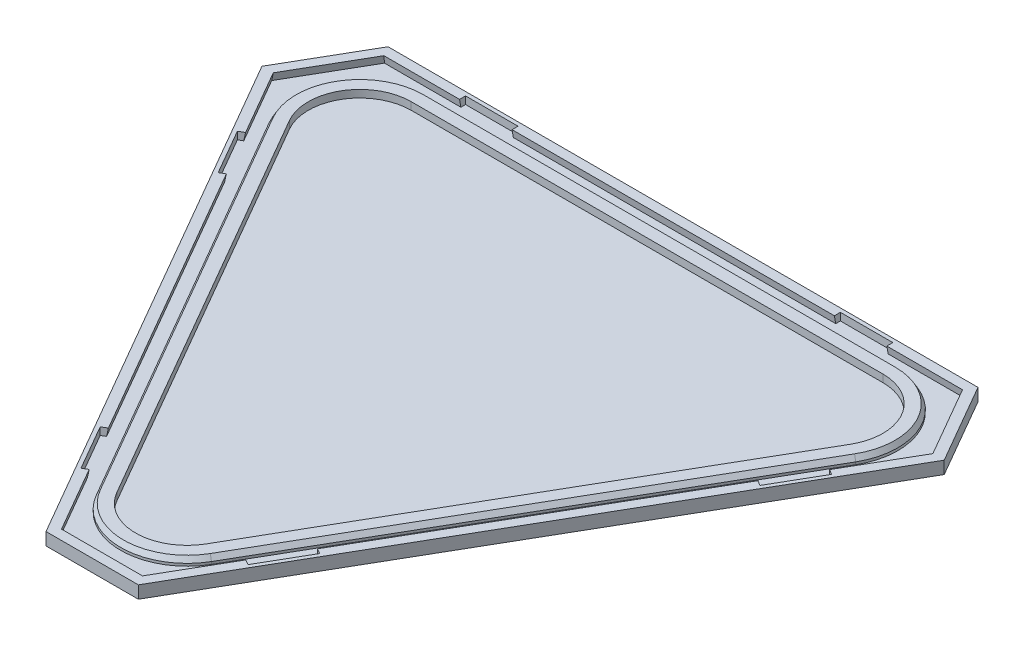
from build123d import *
from OCP.BRepFilletAPI import BRepFilletAPI_MakeChamfer

# Parameters (mm, degrees)
BOSS_EXTRU_2_DEPTH              = 1
EXTRU_MINCE1_DEPTH              = 1.5
EXTRU_MINCE1_DRAFT              = -10
ENL_V_DE_MAT_EXTRU_MINCE1_DEPTH = 101.734373448
ESQUISSE10_W                    = 10.5
ESQUISSE10_H                    = 4.277647959
ENL_V_MAT_EXTRU_1_DEPTH         = 1.5
EXTRU_MINCE2_DEPTH              = 1.5
CHANFREIN1_SIZE                 = 1
CHANFREIN1_SIZE2                = 0.577350269


with BuildPart() as part:
    # Esquisse2 → Boss.-Extru.2 (new body)
    with BuildSketch(Plane(origin=(0, 0, 0), x_dir=(1, 0, 0), z_dir=(0, 1, 0))):
        Polygon((-68.262395693, 28.744645862), (-59.024791386, 44.744645862), (59.024791386, 44.744645862), (68.262395693, 28.744645862), (9.237604307, -73.489291724), (-9.237604307, -73.489291724), align=None)
    extrude(amount=BOSS_EXTRU_2_DEPTH)


with BuildPart() as extru_mince1_tool:
    # Esquisse5 → Extru.-Mince1 (with draft: the straight prism first)
    with BuildSketch(Plane(origin=(0, 1, 0), x_dir=(1, 0, 0), z_dir=(0, 1, 0))):
        Polygon((-68.262395693, 28.744645862), (-9.237604307, -73.489291724), (9.237604307, -73.489291724), (68.262395693, 28.744645862), (59.024791386, 44.744645862), (-59.024791386, 44.744645862), align=None)
        Polygon((-66.299404778, 28.744645862), (-8.256108849, -71.789291724), (8.256108849, -71.789291724), (66.299404778, 28.744645862), (58.043295928, 43.044645862), (-58.043295928, 43.044645862), align=None, mode=Mode.SUBTRACT)
    extrude(amount=EXTRU_MINCE1_DEPTH)
    # Extru.-Mince1: the draft: its side faces are tilted about the plane it starts from
    extru_mince1_sides = [extru_mince1_tool.faces().sort_by_distance(p)[0] for p in [
        (-38.75, 1.75, 22.372322931),
        (0, 1.75, 73.489291724),
        (38.75, 1.75, 22.372322931),
        (63.643593539, 1.75, -36.744645862),
        (0, 1.75, -44.744645862),
        (-63.643593539, 1.75, -36.744645862),
        (-62.171350353, 1.75, -35.894645862),
        (0, 1.75, -43.044645862),
        (62.171350353, 1.75, -35.894645862),
        (37.277756814, 1.75, 21.522322931),
        (0, 1.75, 71.789291724),
        (-37.277756814, 1.75, 21.522322931),
    ]]
    draft(extru_mince1_sides, Plane(origin=(0, 1, 0), x_dir=(1, 0, 0), z_dir=(0, 1, 0)), EXTRU_MINCE1_DRAFT)


with BuildPart() as part_1:
    add(part.part)

    # Extru.-Mince1: add extru_mince1_tool
    add(extru_mince1_tool.part)

    # Esquisse6 → Enlèv. de mat.-Extru.-Mince1 (cut, through all)
    with BuildSketch(Plane.XZ):
        Polygon((-59.89081679, -46.244645862), (59.89081679, -46.244645862), (69.994446501, -28.744645862), (10.103629711, 74.989291724), (-10.103629711, 74.989291724), (-69.994446501, -28.744645862), align=None)
        Polygon((-59.024791386, -44.744645862), (59.024791386, -44.744645862), (68.262395693, -28.744645862), (9.237604307, 73.489291724), (-9.237604307, 73.489291724), (-68.262395693, -28.744645862), align=None, mode=Mode.SUBTRACT)
    extrude(amount=-ENL_V_DE_MAT_EXTRU_MINCE1_DEPTH, mode=Mode.SUBTRACT)

    # Esquisse10 → Enlèv. mat.-Extru.1 (cut)
    with BuildSketch(Plane(origin=(0, 2.5, 0), x_dir=(1, 0, 0), z_dir=(0, 1, 0))):
        with Locations((-37.5, 41.841331412)):
            Rectangle(ESQUISSE10_W, ESQUISSE10_H)
        with Locations((37.5, 41.841331412)):
            Rectangle(ESQUISSE10_W, ESQUISSE10_H)
        Polygon((54.212931831, 5.939241576), (59.462931831, 15.032508316), (55.75838003, 17.171332296), (50.50838003, 8.078065556), align=None)
        Polygon((16.712931831, -59.012663707), (13.00838003, -56.873839728), (18.25838003, -47.780572988), (21.962931831, -49.919396968), align=None)
        Polygon((-21.962931831, -49.919396968), (-16.712931831, -59.012663707), (-13.00838003, -56.873839728), (-18.25838003, -47.780572988), align=None)
        Polygon((-59.462931831, 15.032508316), (-55.75838003, 17.171332296), (-50.50838003, 8.078065556), (-54.212931831, 5.939241576), align=None)
    extrude(amount=-ENL_V_MAT_EXTRU_1_DEPTH, mode=Mode.SUBTRACT)


with BuildPart() as body_2:
    # Esquisse11 → Extru.-Mince2 (new body)
    with BuildSketch(Plane(origin=(0, 1, 0), x_dir=(1, 0, 0), z_dir=(0, 1, 0))):
        with BuildLine():
            Line((-58.707248738, 20.594645862), (-11.51813787, -61.139291724))
            ThreePointArc((-11.51813787, -61.139291724), (0, -67.789291724), (11.51813787, -61.139291724))
            Line((11.51813787, -61.139291724), (58.707248738, 20.594645862))
            ThreePointArc((58.707248738, 20.594645862), (58.707248738, 33.894645862), (47.189110868, 40.544645862))
            Line((47.189110868, 40.544645862), (-47.189110868, 40.544645862))
            ThreePointArc((-47.189110868, 40.544645862), (-58.707248738, 33.894645862), (-58.707248738, 20.594645862))
        make_face()
        with BuildLine():
            Line((-56.109172527, 22.094645862), (-8.920061659, -59.639291724))
            ThreePointArc((-8.920061659, -59.639291724), (0, -64.789291724), (8.920061659, -59.639291724))
            Line((8.920061659, -59.639291724), (56.109172527, 22.094645862))
            ThreePointArc((56.109172527, 22.094645862), (56.109172527, 32.394645862), (47.189110868, 37.544645862))
            Line((47.189110868, 37.544645862), (-47.189110868, 37.544645862))
            ThreePointArc((-47.189110868, 37.544645862), (-56.109172527, 32.394645862), (-56.109172527, 22.094645862))
        make_face(mode=Mode.SUBTRACT)
    extrude(amount=EXTRU_MINCE2_DEPTH)

    # Chanfrein1: one chamfer whose edges measure the first distance from different faces: ONE call of the kernel's chamfer builder (chamfer() names one face for all edges)
    chanfrein1_edges_1 = [body_2.edges().sort_by_distance(p)[0] for p in [
        (35.112693304, 2.5, 20.272322931),
    ]]
    chanfrein1_side_1 = [body_2.faces().sort_by_distance(p)[0] for p in [
        (35.112693304, 1.75, 20.272322931),
    ]]
    chanfrein1_edges_2 = [body_2.edges().sort_by_distance(p)[0] for p in [
        (58.707248738, 2.5, -33.894645862),
    ]]
    chanfrein1_side_2 = [body_2.faces().sort_by_distance(p)[0] for p in [
        (58.707248738, 1.75, -33.894645862),
    ]]
    chanfrein1_edges_3 = [body_2.edges().sort_by_distance(p)[0] for p in [
        (0, 2.5, -40.544645862),
    ]]
    chanfrein1_side_3 = [body_2.faces().sort_by_distance(p)[0] for p in [
        (0, 1.75, -40.544645862),
    ]]
    chanfrein1_edges_4 = [body_2.edges().sort_by_distance(p)[0] for p in [
        (-58.707248738, 2.5, -33.894645862),
    ]]
    chanfrein1_side_4 = [body_2.faces().sort_by_distance(p)[0] for p in [
        (-58.707248738, 1.75, -33.894645862),
    ]]
    chanfrein1_edges_5 = [body_2.edges().sort_by_distance(p)[0] for p in [
        (-35.112693304, 2.5, 20.272322931),
    ]]
    chanfrein1_side_5 = [body_2.faces().sort_by_distance(p)[0] for p in [
        (-35.112693304, 1.75, 20.272322931),
    ]]
    chanfrein1_edges_6 = [body_2.edges().sort_by_distance(p)[0] for p in [
        (0, 2.5, 67.789291724),
    ]]
    chanfrein1_side_6 = [body_2.faces().sort_by_distance(p)[0] for p in [
        (0, 1.75, 67.789291724),
    ]]
    chanfrein1 = BRepFilletAPI_MakeChamfer(body_2.part.solid().wrapped)
    for e in chanfrein1_edges_1:
        chanfrein1.Add(CHANFREIN1_SIZE, CHANFREIN1_SIZE2, e.wrapped, chanfrein1_side_1[0].wrapped)  # the first distance lies on this face
    for e in chanfrein1_edges_2:
        chanfrein1.Add(CHANFREIN1_SIZE, CHANFREIN1_SIZE2, e.wrapped, chanfrein1_side_2[0].wrapped)  # the first distance lies on this face
    for e in chanfrein1_edges_3:
        chanfrein1.Add(CHANFREIN1_SIZE, CHANFREIN1_SIZE2, e.wrapped, chanfrein1_side_3[0].wrapped)  # the first distance lies on this face
    for e in chanfrein1_edges_4:
        chanfrein1.Add(CHANFREIN1_SIZE, CHANFREIN1_SIZE2, e.wrapped, chanfrein1_side_4[0].wrapped)  # the first distance lies on this face
    for e in chanfrein1_edges_5:
        chanfrein1.Add(CHANFREIN1_SIZE, CHANFREIN1_SIZE2, e.wrapped, chanfrein1_side_5[0].wrapped)  # the first distance lies on this face
    for e in chanfrein1_edges_6:
        chanfrein1.Add(CHANFREIN1_SIZE, CHANFREIN1_SIZE2, e.wrapped, chanfrein1_side_6[0].wrapped)  # the first distance lies on this face
    add(Compound.cast(chanfrein1.Shape()), mode=Mode.REPLACE)


solid = Compound([part_1.part, body_2.part])
